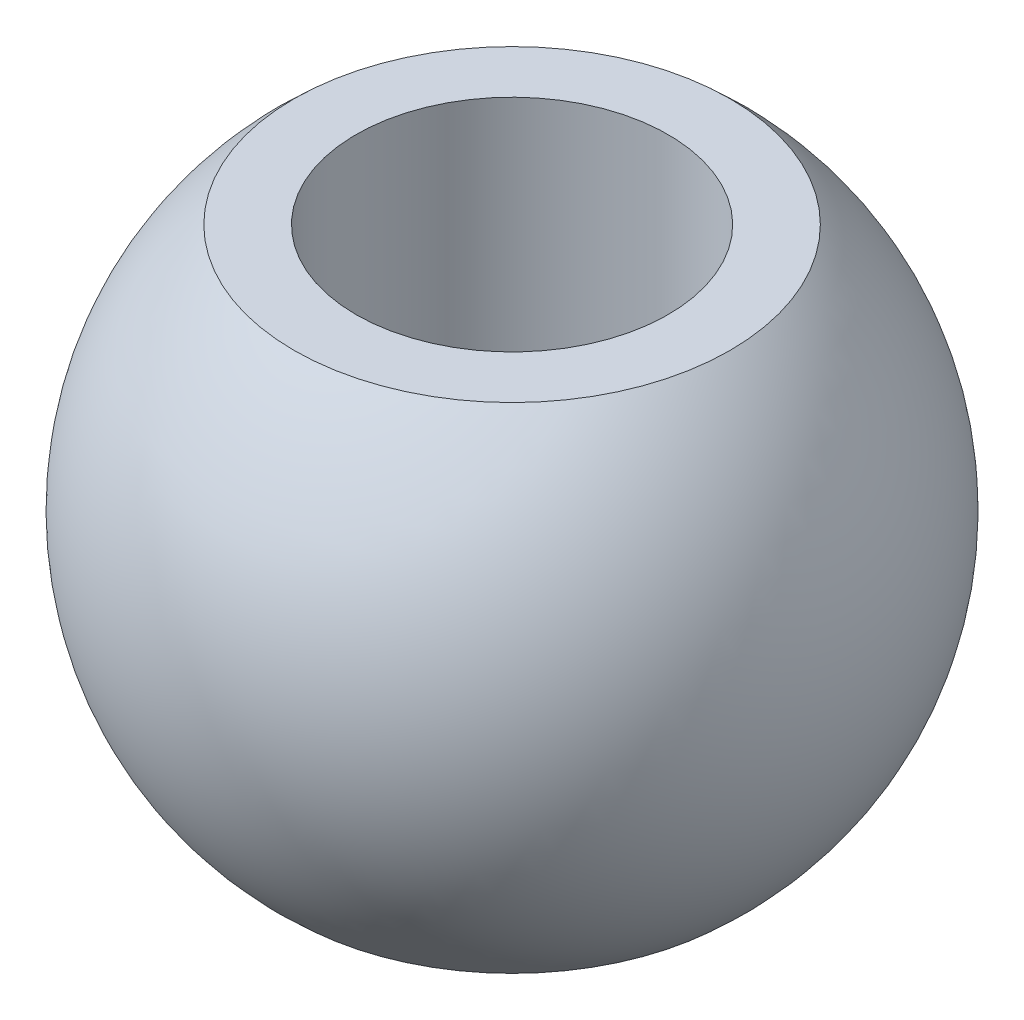
from build123d import *

# Parameters (mm, degrees)
SKETCH2_R      = 2.3876
EXTRUDE1_DEPTH = 1.5969
SKETCH3_R      = 1.1303
EXTRUDE2_DEPTH = 4.5814


with BuildPart() as part:
    # Sketch1 → Revolve1 (revolve)
    with BuildSketch(Plane.XY):
        with BuildLine():
            Line((0, 2.3876), (0, -2.3876))
            ThreePointArc((0, -2.3876), (2.3876, 0), (0, 2.3876))
        make_face()
    revolve(axis=Axis((0, 2.3876, 0), (0, -1, 0)))

    # Sketch2 → Extrude1 (cut, through all)
    with BuildSketch(Plane(origin=(0, 1.7907, 0), x_dir=(-1, 0, 0), z_dir=(0, 1, 0))):
        Circle(SKETCH2_R)
    extrude1 = extrude(amount=EXTRUDE1_DEPTH, mode=Mode.SUBTRACT)

    # Mirror1: Extrude1 across plane
    add(extrude1.mirror(Plane.ZX), mode=Mode.SUBTRACT)

    # Sketch3 → Extrude2 (cut, through all)
    with BuildSketch(Plane(origin=(0, 1.7907, 0), x_dir=(-1, 0, 0), z_dir=(0, 1, 0))):
        Circle(SKETCH3_R)
    extrude(amount=-EXTRUDE2_DEPTH, mode=Mode.SUBTRACT)


solid = part.part
